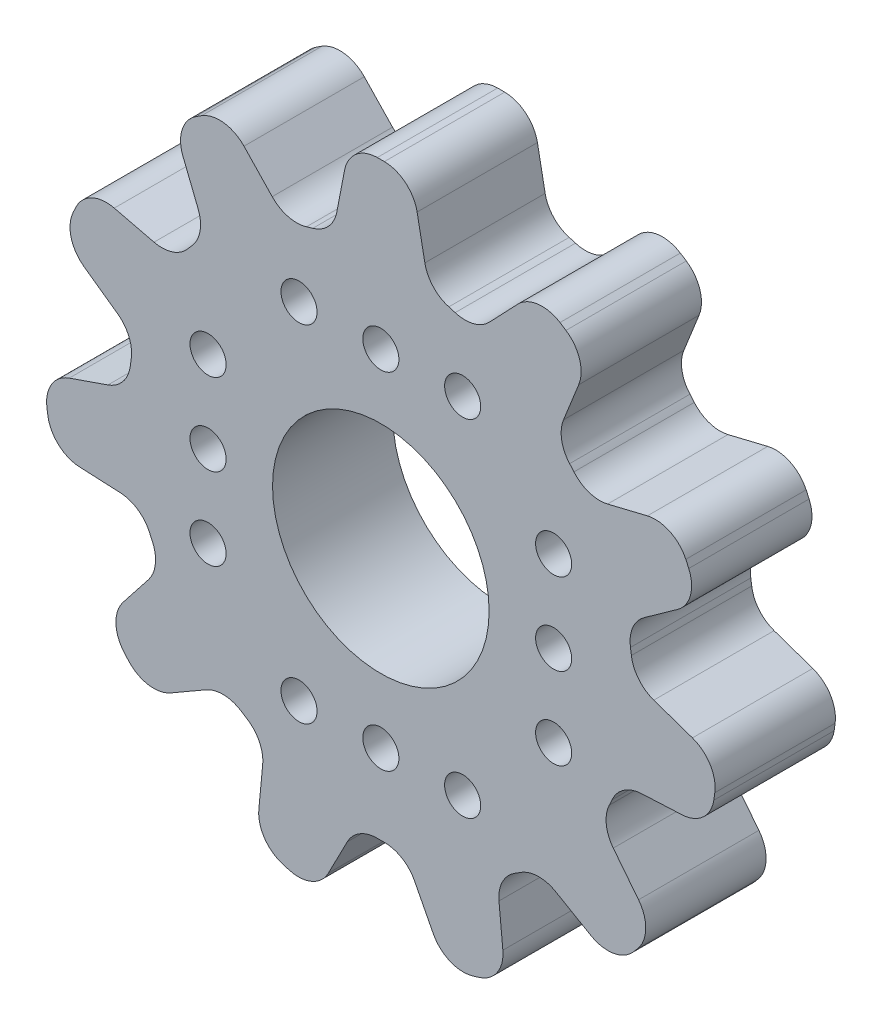
from build123d import *

# Parameters (mm, degrees)
ESBO_O1_R                = 4.5
ESBO_O1_R_2              = 0.75
RESSALTO_EXTRUS_O1_DEPTH = 5


with BuildPart() as part:
    # Esboço1 → Ressalto-extrusão1 (new body)
    with BuildSketch(Plane.XY):
        with BuildLine():
            Line((4.514334386, 10.407189323), (5.686971288, 11.63699072))
            ThreePointArc((5.686971288, 11.63699072), (6.526679908, 12.060076339), (7.444654683, 11.856522115))
            ThreePointArc((7.444654683, 11.856522115), (7.568971444, 11.77754946), (7.692450547, 11.697273382))
            ThreePointArc((7.692450547, 11.697273382), (8.258950485, 10.946813637), (8.222925837, 10.007231691))
            Line((8.222925837, 10.007231691), (7.591390112, 8.429685683))
            ThreePointArc((7.591390112, 8.429685683), (7.512037525, 7.668211946), (7.845097462, 6.978857056))
            ThreePointArc((7.845097462, 6.978857056), (7.935370531, 6.876037706), (8.024296131, 6.772050768))
            ThreePointArc((8.024296131, 6.772050768), (8.65923501, 6.344275472), (9.424251093, 6.314451352))
            Line((9.424251093, 6.314451352), (11.075616863, 6.715050749))
            ThreePointArc((11.075616863, 6.715050749), (12.010762061, 6.616992265), (12.672961861, 5.949456923))
            ThreePointArc((12.672961861, 5.949456923), (12.734847935, 5.815810182), (12.795324642, 5.681519805))
            ThreePointArc((12.795324642, 5.681519805), (12.866165546, 4.743919904), (12.327883333, 3.972969668))
            Line((12.327883333, 3.972969668), (10.94371591, 2.987287505))
            ThreePointArc((10.94371591, 2.987287505), (10.465276482, 2.389596282), (10.372770939, 1.629608249))
            ThreePointArc((10.372770939, 1.629608249), (10.39312514, 1.494305802), (10.411714532, 1.358749614))
            ThreePointArc((10.411714532, 1.358749614), (10.714586321, 0.655608259), (11.342034667, 0.216919693))
            Line((11.342034667, 0.216919693), (12.94783234, -0.338870389))
            ThreePointArc((12.94783234, -0.338870389), (13.681512123, -0.926940099), (13.877693191, -1.846518805))
            ThreePointArc((13.877693191, -1.846518805), (13.857500186, -1.992407736), (13.835773571, -2.138076166))
            ThreePointArc((13.835773571, -2.138076166), (13.388463955, -2.96513488), (12.518824975, -3.322682154))
            Line((12.518824975, -3.322682154), (10.82148923, -3.403553348))
            ThreePointArc((10.82148923, -3.403553348), (10.095864099, -3.647699318), (9.607162934, -4.237029663))
            ThreePointArc((9.607162934, -4.237029663), (9.551135951, -4.361857637), (9.493487134, -4.485944943))
            ThreePointArc((9.493487134, -4.485944943), (9.368132181, -5.241209943), (9.658802374, -5.949482436))
            Line((9.658802374, -5.949482436), (10.709202535, -7.285202572))
            ThreePointArc((10.709202535, -7.285202572), (11.008478755, -8.176575531), (10.676354988, -9.05623786))
            ThreePointArc((10.676354988, -9.05623786), (10.580494041, -9.168050275), (10.48346215, -9.278848062))
            ThreePointArc((10.48346215, -9.278848062), (9.660019656, -9.73278029), (8.735128141, -9.563405868))
            Line((8.735128141, -9.563405868), (7.263516181, -8.713790062))
            ThreePointArc((7.263516181, -8.713790062), (6.521086199, -8.526876158), (5.791348577, -8.758440595))
            ThreePointArc((5.791348577, -8.758440595), (5.676728583, -8.833162095), (5.56114465, -8.906383676))
            ThreePointArc((5.56114465, -8.906383676), (5.047362265, -9.473981021), (4.908968572, -10.226965929))
            Line((4.908968572, -10.226965929), (5.070476592, -11.918534414))
            ThreePointArc((5.070476592, -11.918534414), (4.840331165, -12.830206005), (4.085349512, -13.390665382))
            ThreePointArc((4.085349512, -13.390665382), (3.944255796, -13.432901631), (3.802725568, -13.473651259))
            ThreePointArc((3.802725568, -13.473651259), (2.864587371, -13.410336727), (2.178089842, -12.767815792))
            Line((2.178089842, -12.767815792), (1.399428066, -11.257459999))
            ThreePointArc((1.399428066, -11.257459999), (0.875909507, -10.698830065), (0.136821968, -10.499108522))
            ThreePointArc((0.136821968, -10.499108522), (0, -10.5), (-0.136821968, -10.499108522))
            ThreePointArc((-0.136821968, -10.499108522), (-0.875909507, -10.698830065), (-1.399428066, -11.257459999))
            Line((-1.399428066, -11.257459999), (-2.178089842, -12.767815792))
            ThreePointArc((-2.178089842, -12.767815792), (-2.864587371, -13.410336727), (-3.802725568, -13.473651259))
            ThreePointArc((-3.802725568, -13.473651259), (-3.944255796, -13.432901631), (-4.085349512, -13.390665382))
            ThreePointArc((-4.085349512, -13.390665382), (-4.840331165, -12.830206005), (-5.070476592, -11.918534414))
            Line((-5.070476592, -11.918534414), (-4.908968572, -10.226965929))
            ThreePointArc((-4.908968572, -10.226965929), (-5.047362265, -9.473981021), (-5.56114465, -8.906383676))
            ThreePointArc((-5.56114465, -8.906383676), (-5.676728583, -8.833162095), (-5.791348577, -8.758440595))
            ThreePointArc((-5.791348577, -8.758440595), (-6.521086199, -8.526876158), (-7.263516181, -8.713790062))
            Line((-7.263516181, -8.713790062), (-8.735128141, -9.563405868))
            ThreePointArc((-8.735128141, -9.563405868), (-9.660019656, -9.73278029), (-10.48346215, -9.278848062))
            ThreePointArc((-10.48346215, -9.278848062), (-10.580494041, -9.168050275), (-10.676354988, -9.05623786))
            ThreePointArc((-10.676354988, -9.05623786), (-11.008478755, -8.176575531), (-10.709202535, -7.285202572))
            Line((-10.709202535, -7.285202572), (-9.658802374, -5.949482436))
            ThreePointArc((-9.658802374, -5.949482436), (-9.368132181, -5.241209943), (-9.493487134, -4.485944943))
            ThreePointArc((-9.493487134, -4.485944943), (-9.551135951, -4.361857637), (-9.607162934, -4.237029663))
            ThreePointArc((-9.607162934, -4.237029663), (-10.095864099, -3.647699318), (-10.82148923, -3.403553348))
            Line((-10.82148923, -3.403553348), (-12.518824975, -3.322682154))
            ThreePointArc((-12.518824975, -3.322682154), (-13.388463955, -2.96513488), (-13.835773571, -2.138076166))
            ThreePointArc((-13.835773571, -2.138076166), (-13.857500186, -1.992407736), (-13.877693191, -1.846518805))
            ThreePointArc((-13.877693191, -1.846518805), (-13.681512123, -0.926940099), (-12.94783234, -0.338870389))
            Line((-12.94783234, -0.338870389), (-11.342034667, 0.216919693))
            ThreePointArc((-11.342034667, 0.216919693), (-10.714586321, 0.655608259), (-10.411714532, 1.358749614))
            ThreePointArc((-10.411714532, 1.358749614), (-10.39312514, 1.494305802), (-10.372770939, 1.629608249))
            ThreePointArc((-10.372770939, 1.629608249), (-10.465276482, 2.389596282), (-10.94371591, 2.987287505))
            Line((-10.94371591, 2.987287505), (-12.327883333, 3.972969668))
            ThreePointArc((-12.327883333, 3.972969668), (-12.866165546, 4.743919904), (-12.795324642, 5.681519805))
            ThreePointArc((-12.795324642, 5.681519805), (-12.734847935, 5.815810182), (-12.672961861, 5.949456923))
            ThreePointArc((-12.672961861, 5.949456923), (-12.010762061, 6.616992265), (-11.075616863, 6.715050749))
            Line((-11.075616863, 6.715050749), (-9.424251093, 6.314451352))
            ThreePointArc((-9.424251093, 6.314451352), (-8.65923501, 6.344275472), (-8.024296131, 6.772050768))
            ThreePointArc((-8.024296131, 6.772050768), (-7.935370531, 6.876037706), (-7.845097462, 6.978857056))
            ThreePointArc((-7.845097462, 6.978857056), (-7.512037525, 7.668211946), (-7.591390112, 8.429685683))
            Line((-7.591390112, 8.429685683), (-8.222925837, 10.007231691))
            ThreePointArc((-8.222925837, 10.007231691), (-8.258950485, 10.946813637), (-7.692450547, 11.697273382))
            ThreePointArc((-7.692450547, 11.697273382), (-7.568971444, 11.77754946), (-7.444654683, 11.856522115))
            ThreePointArc((-7.444654683, 11.856522115), (-6.526679908, 12.060076339), (-5.686971288, 11.63699072))
            Line((-5.686971288, 11.63699072), (-4.514334386, 10.407189323))
            ThreePointArc((-4.514334386, 10.407189323), (-3.854637767, 10.018680048), (-3.089220405, 10.035273653))
            ThreePointArc((-3.089220405, 10.035273653), (-2.958191847, 10.074676223), (-2.826660972, 10.112368059))
            ThreePointArc((-2.826660972, 10.112368059), (-2.173779732, 10.512224498), (-1.828851593, 11.195718217))
            Line((-1.828851593, 11.195718217), (-1.507247489, 12.864268361))
            ThreePointArc((-1.507247489, 12.864268361), (-1.029577, 13.674171387), (-0.147277756, 13.999225309))
            ThreePointArc((-0.147277756, 13.999225309), (0, 14), (0.147277756, 13.999225309))
            ThreePointArc((0.147277756, 13.999225309), (1.029577, 13.674171387), (1.507247489, 12.864268361))
            Line((1.507247489, 12.864268361), (1.828851593, 11.195718217))
            ThreePointArc((1.828851593, 11.195718217), (2.173779732, 10.512224498), (2.826660972, 10.112368059))
            ThreePointArc((2.826660972, 10.112368059), (2.958191847, 10.074676223), (3.089220405, 10.035273653))
            ThreePointArc((3.089220405, 10.035273653), (3.854637767, 10.018680048), (4.514334386, 10.407189323))
        make_face()
        Circle(ESBO_O1_R, mode=Mode.SUBTRACT)
        with Locations((3.4, 7.18)):
            Circle(ESBO_O1_R_2, mode=Mode.SUBTRACT)
        with Locations((0, 7.18)):
            Circle(ESBO_O1_R_2, mode=Mode.SUBTRACT)
        with Locations((-3.4, 7.18)):
            Circle(ESBO_O1_R_2, mode=Mode.SUBTRACT)
        with Locations((7.18, -3.4)):
            Circle(ESBO_O1_R_2, mode=Mode.SUBTRACT)
        with Locations((7.18, 0)):
            Circle(ESBO_O1_R_2, mode=Mode.SUBTRACT)
        with Locations((7.18, 3.4)):
            Circle(ESBO_O1_R_2, mode=Mode.SUBTRACT)
        with Locations((-3.4, -7.18)):
            Circle(ESBO_O1_R_2, mode=Mode.SUBTRACT)
        with Locations((0, -7.18)):
            Circle(ESBO_O1_R_2, mode=Mode.SUBTRACT)
        with Locations((3.4, -7.18)):
            Circle(ESBO_O1_R_2, mode=Mode.SUBTRACT)
        with Locations((-7.18, 3.4)):
            Circle(ESBO_O1_R_2, mode=Mode.SUBTRACT)
        with Locations((-7.18, 0)):
            Circle(ESBO_O1_R_2, mode=Mode.SUBTRACT)
        with Locations((-7.18, -3.4)):
            Circle(ESBO_O1_R_2, mode=Mode.SUBTRACT)
    extrude(amount=RESSALTO_EXTRUS_O1_DEPTH)


solid = part.part
